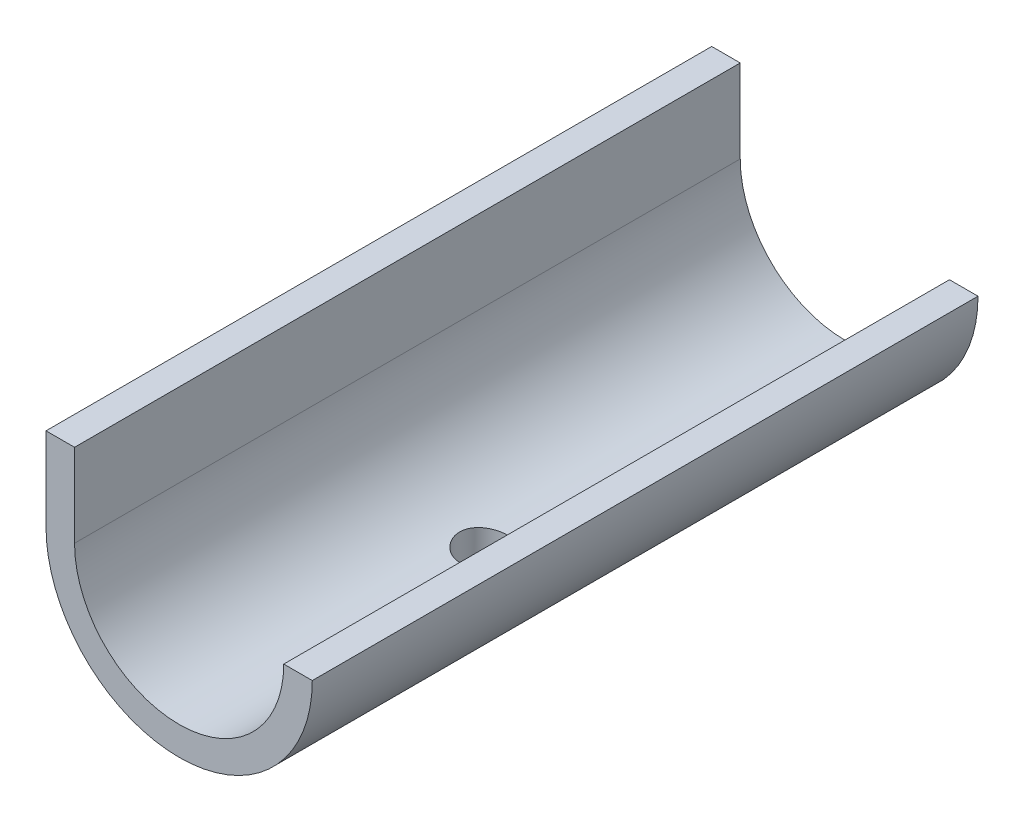
from build123d import *

# Parameters (mm, degrees)
SKETCH2_R           = 14
BOSS_EXTRUDE1_DEPTH = 70
SKETCH3_R           = 11
CUT_EXTRUDE1_DEPTH  = 71
SKETCH4_W           = 32.230614228
SKETCH4_H           = 15.278665706
CUT_EXTRUDE2_DEPTH  = 71
SKETCH5_W           = 3
SKETCH5_H           = 8.740769075
BOSS_EXTRUDE3_DEPTH = 70
SKETCH7_R           = 2.5
CUT_EXTRUDE3_DEPTH  = 15


with BuildPart() as part:
    # Sketch2 → Boss-Extrude1 (new body)
    with BuildSketch(Plane.XY):
        Circle(SKETCH2_R)
    extrude(amount=BOSS_EXTRUDE1_DEPTH)

    # Sketch3 → Cut-Extrude1 (cut, through all)
    with BuildSketch(Plane.XY.offset(70)):
        Circle(SKETCH3_R)
    extrude(amount=-CUT_EXTRUDE1_DEPTH, mode=Mode.SUBTRACT)

    # Sketch4 → Cut-Extrude2 (cut, through all)
    with BuildSketch(Plane.XY.offset(70)):
        with Locations((0.085938844, 7.639332853)):
            Rectangle(SKETCH4_W, SKETCH4_H)
    extrude(amount=-CUT_EXTRUDE2_DEPTH, mode=Mode.SUBTRACT)

    # Sketch5 → Boss-Extrude3 (add)
    with BuildSketch(Plane.XY.offset(70)):
        with Locations((-12.5, 4.370384538)):
            Rectangle(SKETCH5_W, SKETCH5_H)
    extrude(amount=-BOSS_EXTRUDE3_DEPTH)

    # Sketch7 → Cut-Extrude3 (cut, through all)
    with BuildSketch(Plane(origin=(0, 0, 0), x_dir=(1, 0, 0), z_dir=(0, 1, 0))):
        with Locations((0, -38)):
            Circle(SKETCH7_R)
    extrude(amount=-CUT_EXTRUDE3_DEPTH, mode=Mode.SUBTRACT)


solid = part.part
